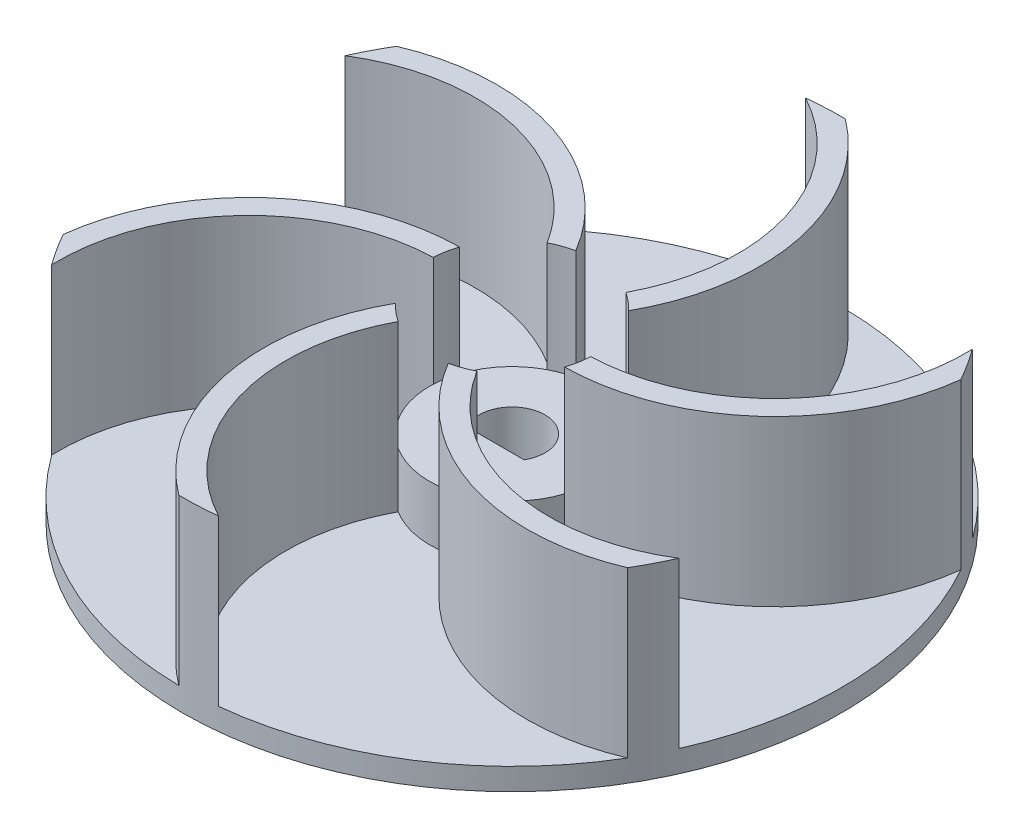
from build123d import *

# Parameters (mm, degrees)
SKETCH1_R           = 30
BOSS_EXTRUDE1_DEPTH = 2
SKETCH2_R           = 7.5
BOSS_EXTRUDE2_DEPTH = 7
BOSS_EXTRUDE3_DEPTH = 15
CUT_EXTRUDE1_DEPTH  = 18
CIRPATTERN2_COUNT   = 6


with BuildPart() as part:
    # Sketch1 → Boss-Extrude1 (new body)
    with BuildSketch(Plane(origin=(0, 0, 0), x_dir=(1, 0, 0), z_dir=(0, 1, 0))):
        Circle(SKETCH1_R)
    extrude(amount=BOSS_EXTRUDE1_DEPTH)

    # Sketch2 → Boss-Extrude2 (add)
    with BuildSketch(Plane(origin=(0, 0, 0), x_dir=(1, 0, 0), z_dir=(0, 1, 0))):
        Circle(SKETCH2_R)
    extrude(amount=BOSS_EXTRUDE2_DEPTH)

    # Sketch3 → Boss-Extrude3 (add)
    with BuildSketch(Plane(origin=(0, 2, 0), x_dir=(1, 0, 0), z_dir=(0, 1, 0))):
        with BuildLine():
            ThreePointArc((-27.399897799, 12.216611666), (-14.278250642, 14.389995002), (-3.458222056, 6.65512586))
            ThreePointArc((-3.458222056, 6.65512586), (-3.002192418, 6.872906277), (-2.532531954, 7.059481702))
            ThreePointArc((-2.532531954, 7.059481702), (-13.262608044, 15.162164286), (-26.638909527, 13.797409149))
            ThreePointArc((-26.638909527, 13.797409149), (-27.03096196, 13.012574516), (-27.399897799, 12.216611666))
        make_face()
        with BuildLine():
            ThreePointArc((-2.532531954, 7.059481702), (-2.038530942, 7.217644463), (-1.534779322, 7.341284113))
            ThreePointArc((-1.534779322, 7.341284113), (-12.178839524, 15.878170307), (-25.810761164, 15.290670625))
            ThreePointArc((-25.810761164, 15.290670625), (-26.235461619, 14.549933115), (-26.638909527, 13.797409149))
            ThreePointArc((-26.638909527, 13.797409149), (-13.262608044, 15.162164286), (-2.532531954, 7.059481702))
        make_face()
    boss_extrude3 = extrude(amount=BOSS_EXTRUDE3_DEPTH)

    # Sketch4 → Cut-Extrude1 (cut, through all)
    with BuildSketch(Plane(origin=(0, 0, 0), x_dir=(1, 0, 0), z_dir=(0, 1, 0))):
        with BuildLine():
            Line((-2.598076211, -1.5), (2.598076211, -1.5))
            ThreePointArc((2.598076211, -1.5), (0, 3), (-2.598076211, -1.5))
        make_face()
    extrude(amount=CUT_EXTRUDE1_DEPTH, mode=Mode.SUBTRACT)

    # CirPattern2: Boss-Extrude3 ×6 about axis
    cirpattern2_axis = Axis((0, 0, 0), (0, 1, 0))
    for i in range(1, CIRPATTERN2_COUNT):
        add(boss_extrude3.rotate(cirpattern2_axis, i * 360 / CIRPATTERN2_COUNT))


solid = part.part
